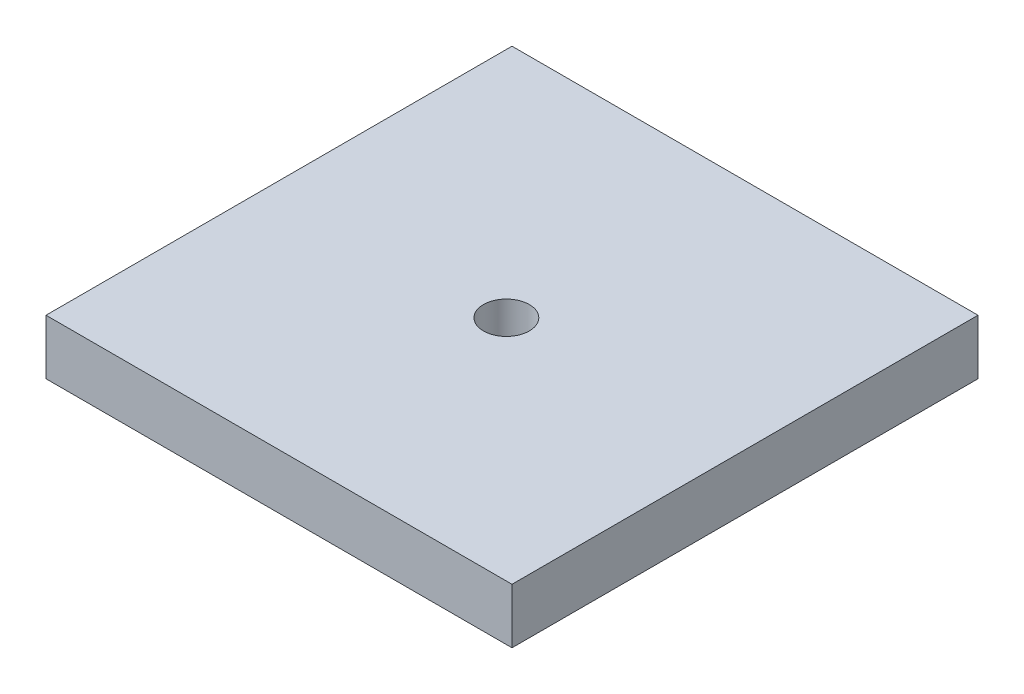
from build123d import *

# Parameters (mm, degrees)
SKETCH1_W             = 25.4
SKETCH1_H             = 25.4
BOSS_EXTRUDE1_DEPTH   = 3
M3X0_5_TAPPED_HOLE1_D = 2.5


with BuildPart() as part:
    # Sketch1 → Boss-Extrude1 (new body)
    with BuildSketch(Plane(origin=(0, 0, 0), x_dir=(1, 0, 0), z_dir=(0, 1, 0))):
        Rectangle(SKETCH1_W, SKETCH1_H)
    extrude(amount=BOSS_EXTRUDE1_DEPTH)

    # M3x0.5 Tapped Hole1 (through all)
    with Locations(Plane(origin=(-0.033999566, 3, 0.27199653), x_dir=(0, 0, 1), z_dir=(0, 1, 0))):
        with Locations((0, 0)):
            Hole(M3X0_5_TAPPED_HOLE1_D / 2)


solid = part.part
